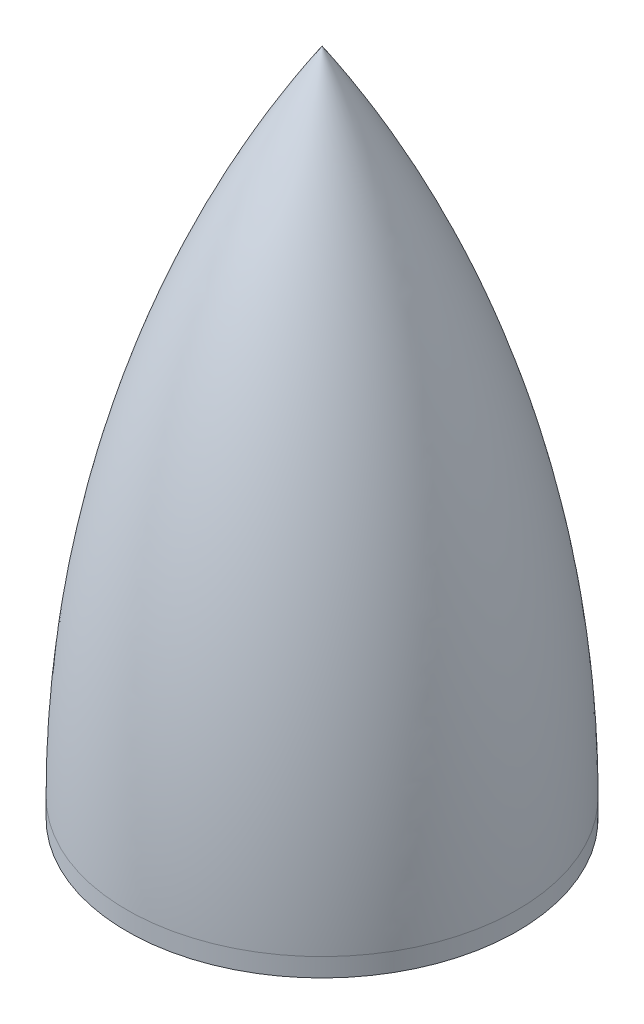
from build123d import *


with BuildPart() as part:
    # Sketch1 → Revolve1 (revolve)
    with BuildSketch(Plane.XY):
        with BuildLine():
            Line((-1.5875, 0), (-22.225, 0))
            Line((-22.225, 0), (-22.225, 2.1082))
            ThreePointArc((-22.225, 2.1082), (-16.549088511, 40.784890177), (0, 76.2))
            Line((0, 76.2), (0, 73.845140026))
            ThreePointArc((0, 73.845140026), (-15.674539498, 39.477580428), (-21.1836, 2.1082))
            Line((-21.1836, 2.1082), (-6.35, 2.1082))
            Line((-6.35, 2.1082), (-6.35, 6.35))
            Line((-6.35, 6.35), (-1.5875, 6.35))
            Line((-1.5875, 6.35), (-1.5875, 2.1082))
            Line((-1.5875, 2.1082), (-1.5875, 0))
        make_face()
    revolve(axis=Axis((0, 0, 0), (0, 1, 0)))


solid = part.part
